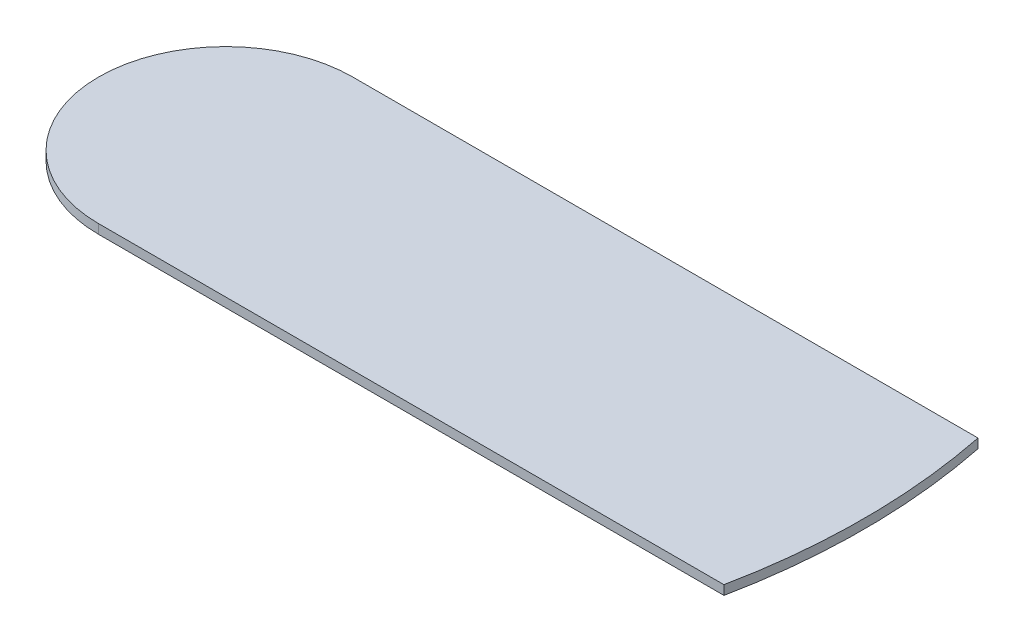
from build123d import *

# Parameters (mm, degrees)
BOSS_EXTRUDE1_DEPTH = 1.95


with BuildPart() as part:
    # Sketch1 → Boss-Extrude1 (new body)
    with BuildSketch(Plane(origin=(0, 0, 0), x_dir=(1, 0, 0), z_dir=(0, 1, 0))):
        with BuildLine():
            Line((0, -26.575), (130.828205579, -26.575))
            ThreePointArc((130.828205579, -26.575), (132.830371988, -13.354485299), (133.5, 0))
            ThreePointArc((133.5, 0), (132.830371988, 13.354485299), (130.828205579, 26.575))
            Line((130.828205579, 26.575), (0, 26.575))
            ThreePointArc((0, 26.575), (-26.575, 0), (0, -26.575))
        make_face()
    extrude(amount=BOSS_EXTRUDE1_DEPTH)


solid = part.part
